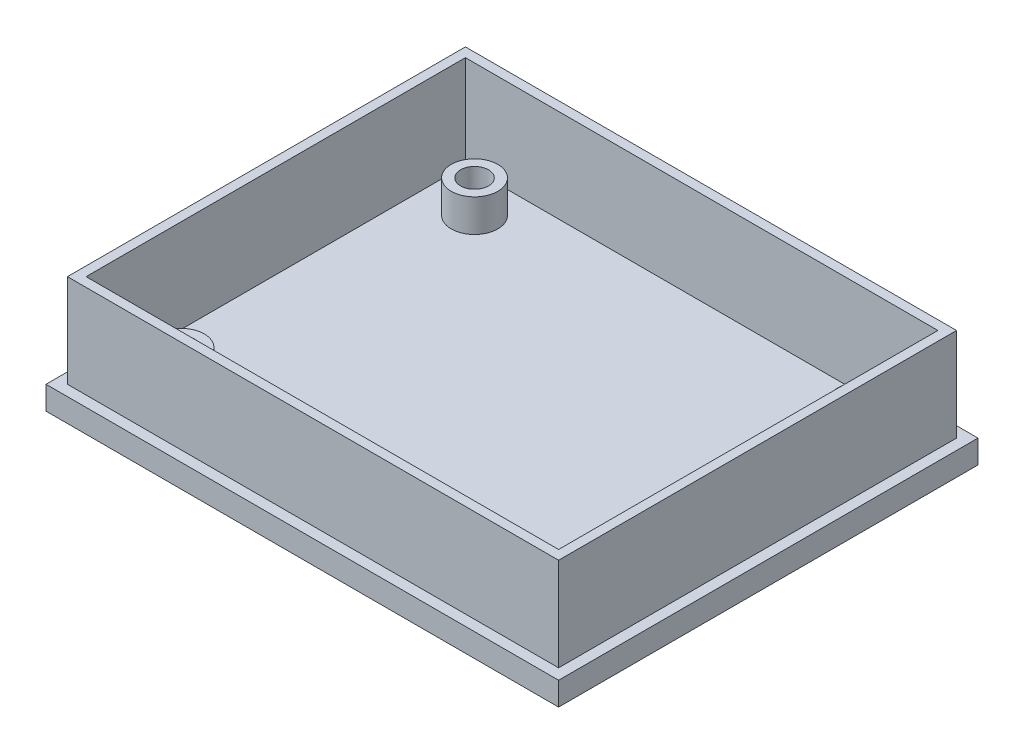
from build123d import *

# Parameters (mm, degrees)
SKETCH1_W           = 110
SKETCH1_H           = 90
BOSS_EXTRUDE1_DEPTH = 5
SKETCH4_W           = 105.4
SKETCH4_H           = 85.4
SKETCH4_W_2         = 101.4
SKETCH4_H_2         = 81.4
BOSS_EXTRUDE2_DEPTH = 20
SKETCH5_R           = 5
BOSS_EXTRUDE3_DEPTH = 7
SKETCH6_R           = 3
CUT_EXTRUDE1_DEPTH  = 5


with BuildPart() as part:
    # Sketch1 → Boss-Extrude1 (new body)
    with BuildSketch(Plane(origin=(0, 0, 0), x_dir=(1, 0, 0), z_dir=(0, 1, 0))):
        Rectangle(SKETCH1_W, SKETCH1_H)
    extrude(amount=BOSS_EXTRUDE1_DEPTH)

    # Sketch4 → Boss-Extrude2 (add)
    with BuildSketch(Plane(origin=(0, 5, 0), x_dir=(1, 0, 0), z_dir=(0, 1, 0))):
        Rectangle(SKETCH4_W, SKETCH4_H)
        Rectangle(SKETCH4_W_2, SKETCH4_H_2, mode=Mode.SUBTRACT)
    extrude(amount=BOSS_EXTRUDE2_DEPTH)

    # Sketch5 → Boss-Extrude3 (add)
    with BuildSketch(Plane(origin=(0, 5, 0), x_dir=(1, 0, 0), z_dir=(0, 1, 0))):
        with Locations((-40.380300674, 32.341761364)):
            Circle(SKETCH5_R)
        with Locations((-40.380300674, -30.658238636)):
            Circle(SKETCH5_R)
        with Locations((42.619699326, -30.658238636)):
            Circle(SKETCH5_R)
        with Locations((42.619699326, 32.341761364)):
            Circle(SKETCH5_R)
    extrude(amount=BOSS_EXTRUDE3_DEPTH)

    # Sketch6 → Cut-Extrude1 (cut)
    with BuildSketch(Plane(origin=(0, 12, 0), x_dir=(1, 0, 0), z_dir=(0, 1, 0))):
        with Locations((-40.380300674, 32.341761364)):
            Circle(SKETCH6_R)
        with Locations((-40.380300674, -30.658238636)):
            Circle(SKETCH6_R)
        with Locations((42.619699326, -30.658238636)):
            Circle(SKETCH6_R)
        with Locations((42.619699326, 32.341761364)):
            Circle(SKETCH6_R)
    extrude(amount=-CUT_EXTRUDE1_DEPTH, mode=Mode.SUBTRACT)


solid = part.part
